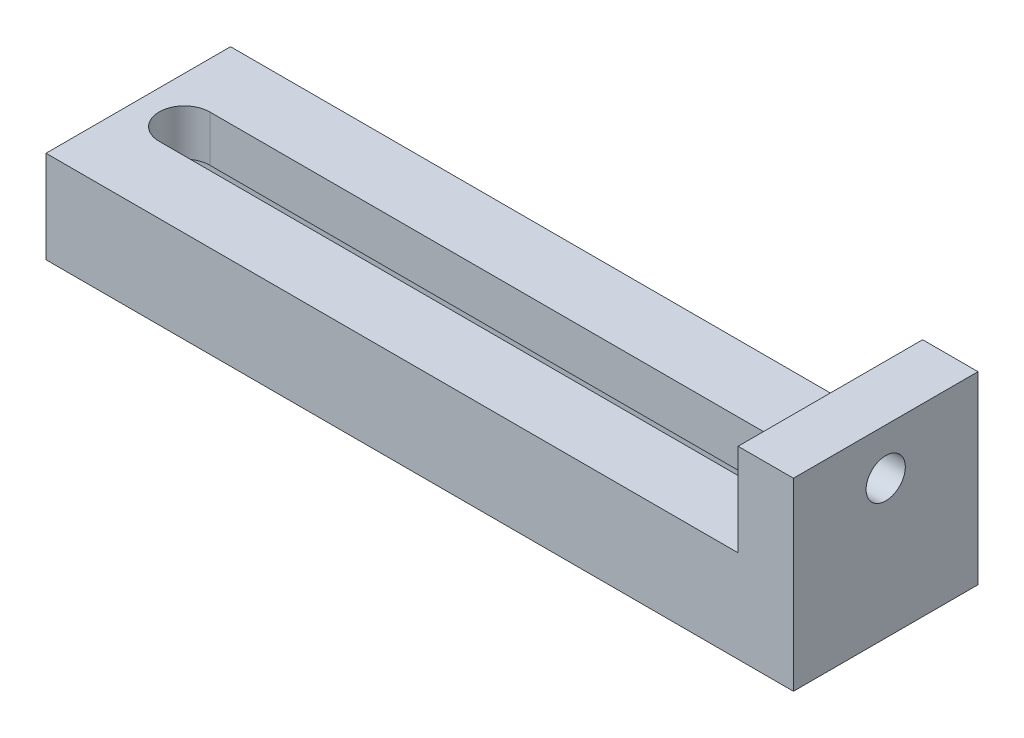
from build123d import *

# Parameters (mm, degrees)
SKETCH_1_W              = 150
SKETCH_1_H              = 40
EXTRUDE_1_DEPTH         = 20
SKETCH_3_W              = 12
SKETCH_3_H              = 40
EXTRUDE_2_DEPTH         = 40
CUT_EXTRUDE_1_DEPTH     = 40
HOLE_WIZARD_M10_1_D     = 8.5
HOLE_WIZARD_M10_1_DEPTH = 24.5
HOLE_WIZARD_M10_1_TIP   = 2.553657631
CUT_EXTRUDE_START       = -150
SKETCH_7_W              = 16
SKETCH_7_H              = 10
CUT_EXTRUDE_2_DEPTH     = 150


with BuildPart() as part:
    # 草图1 → 凸台-拉伸1 (new body)
    with BuildSketch(Plane(origin=(0, 0, 0), x_dir=(1, 0, 0), z_dir=(0, 1, 0))):
        Rectangle(SKETCH_1_W, SKETCH_1_H)
    extrude(amount=EXTRUDE_1_DEPTH)

    # 草图3 → 凸台-拉伸2 (add)
    with BuildSketch(Plane.XZ):
        with Locations((81, 0)):
            Rectangle(SKETCH_3_W, SKETCH_3_H)
    extrude(amount=-EXTRUDE_2_DEPTH)

    # 草图4 → 切除-拉伸1 (cut)
    with BuildSketch(Plane(origin=(0, 20, 0), x_dir=(1, 0, 0), z_dir=(0, 1, 0))):
        with BuildLine():
            Line((-65, -5.5), (65, -5.5))
            ThreePointArc((65, -5.5), (70.5, 0), (65, 5.5))
            Line((65, 5.5), (-65, 5.5))
            ThreePointArc((-65, 5.5), (-70.5, 0), (-65, -5.5))
        make_face()
    extrude(amount=-CUT_EXTRUDE_1_DEPTH, mode=Mode.SUBTRACT)

    # M10 螺纹孔1
    with Locations(Plane(origin=(87, 0, 0), x_dir=(0, 0, -1), z_dir=(1, 0, 0))):
        with Locations((0, 30)):
            Hole(HOLE_WIZARD_M10_1_D / 2, depth=HOLE_WIZARD_M10_1_DEPTH)
            with Locations((0, 0, -(HOLE_WIZARD_M10_1_DEPTH + HOLE_WIZARD_M10_1_TIP / 2))):  # 118° drill point
                Cone(0, HOLE_WIZARD_M10_1_D / 2, HOLE_WIZARD_M10_1_TIP, mode=Mode.SUBTRACT)

    # 草图7 → 切除-拉伸2 (cut)
    with BuildSketch(Plane.ZY.offset(75).offset(CUT_EXTRUDE_START)):
        with Locations((0, 5)):
            Rectangle(SKETCH_7_W, SKETCH_7_H)
    extrude(amount=CUT_EXTRUDE_2_DEPTH, mode=Mode.SUBTRACT)


solid = part.part
